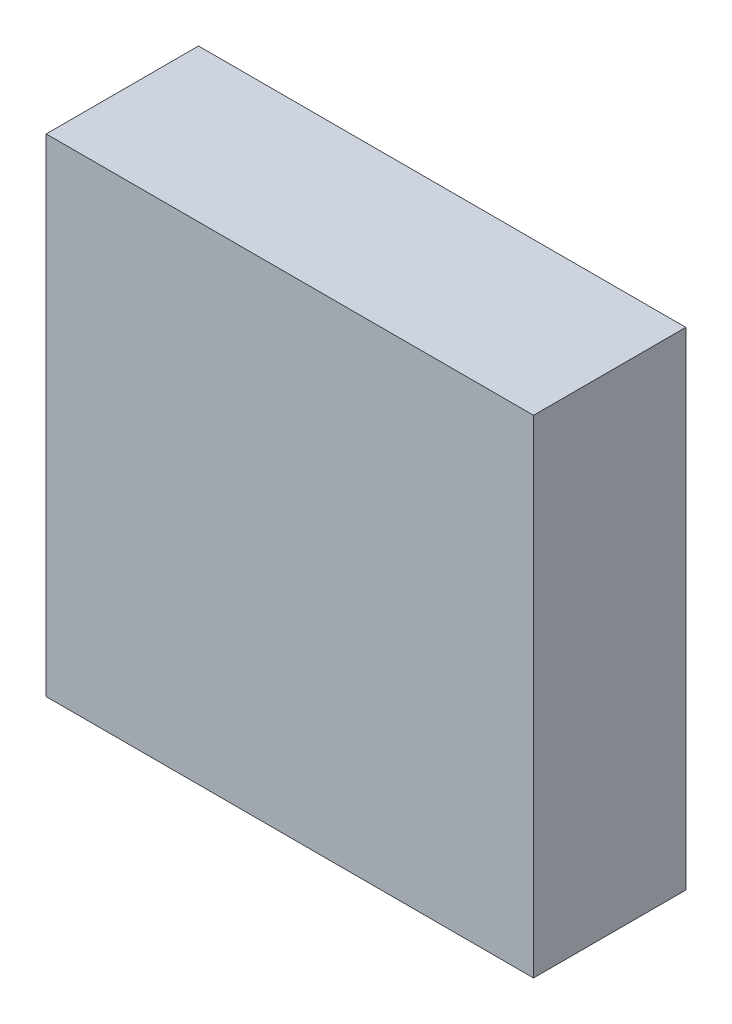
from build123d import *

# Parameters (mm, degrees)
SKETCH1_W           = 80
SKETCH1_H           = 80
BOSS_EXTRUDE1_DEPTH = 25


with BuildPart() as part:
    # Sketch1 → Boss-Extrude1 (new body)
    with BuildSketch(Plane.XY):
        with Locations((5.372654336, 7.636750014)):
            Rectangle(SKETCH1_W, SKETCH1_H)
    extrude(amount=BOSS_EXTRUDE1_DEPTH)


solid = part.part
